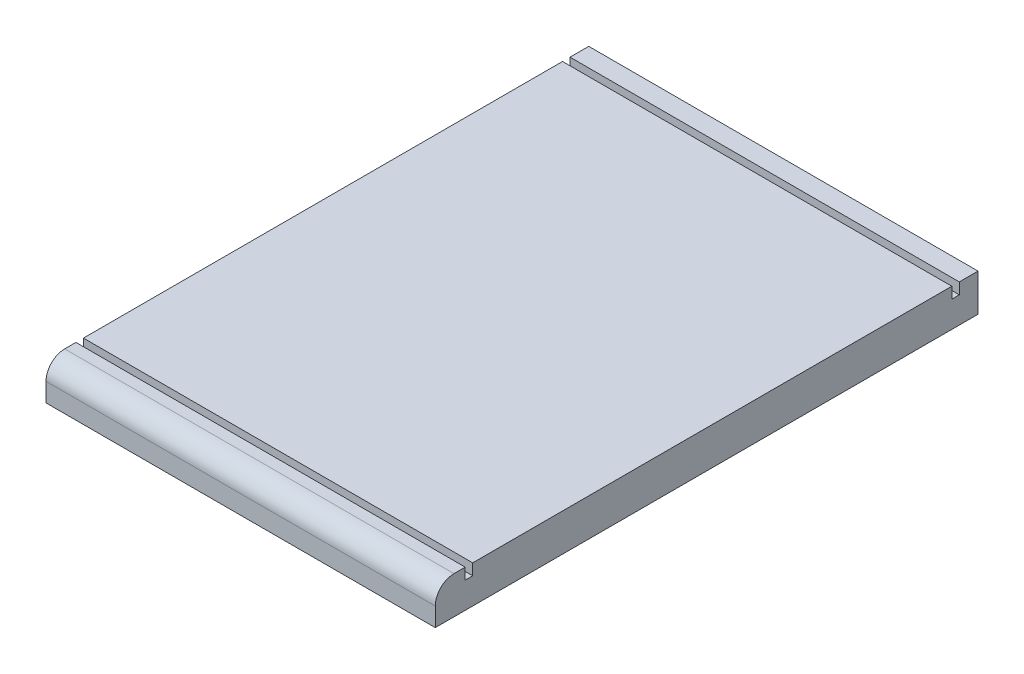
from build123d import *

# Parameters (mm, degrees)
SKETCH1_W           = 104
SKETCH1_H           = 145
BOSS_EXTRUDE1_DEPTH = 10
SKETCH2_W           = 104
SKETCH2_H           = 2
CUT_EXTRUDE1_DEPTH  = 3
FILLET2_R           = 5


with BuildPart() as part:
    # Sketch1 → Boss-Extrude1 (new body)
    with BuildSketch(Plane(origin=(0, 0, 0), x_dir=(1, 0, 0), z_dir=(0, 1, 0))):
        Rectangle(SKETCH1_W, SKETCH1_H)
    extrude(amount=BOSS_EXTRUDE1_DEPTH)

    # Sketch2 → Cut-Extrude1 (cut)
    with BuildSketch(Plane(origin=(0, 10, 0), x_dir=(1, 0, 0), z_dir=(0, 1, 0))):
        with Locations((0, 66.5)):
            Rectangle(SKETCH2_W, SKETCH2_H)
        with Locations((0, -63.5)):
            Rectangle(SKETCH2_W, SKETCH2_H)
    extrude(amount=-CUT_EXTRUDE1_DEPTH, mode=Mode.SUBTRACT)

    # Fillet2
    fillet2_edges = [part.edges().sort_by_distance(p)[0] for p in [
        (0, 10, 72.5),
    ]]
    fillet(fillet2_edges, radius=FILLET2_R)


solid = part.part
